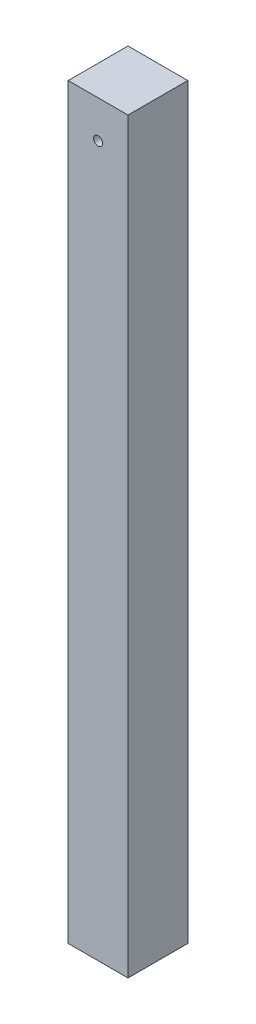
from build123d import *

# Parameters (mm, degrees)
IZIM1_W                     = 80
IZIM1_H                     = 1000
Y_KSEKLIK_EKSTR_ZYON1_DEPTH = 80
KES_EKSTR_ZYON1_REACH       = 82
IZIM2_R                     = 6


with BuildPart() as part:
    # Çizim1 → Yükseklik-Ekstrüzyon1 (new body)
    with BuildSketch(Plane.XY):
        Rectangle(IZIM1_W, IZIM1_H)
    extrude(amount=-Y_KSEKLIK_EKSTR_ZYON1_DEPTH)

    # Çizim2 → Kes-Ekstrüzyon1 (cut, up to next)
    with BuildSketch(Plane.XY, mode=Mode.PRIVATE) as kes_ekstr_zyon1_sk1:
        with Locations((0, 450)):
            Circle(IZIM2_R)
    kes_ekstr_zyon1_tool1 = extrude(kes_ekstr_zyon1_sk1.sketch, amount=-KES_EKSTR_ZYON1_REACH, mode=Mode.PRIVATE) & part.part
    add(kes_ekstr_zyon1_tool1.solids().sort_by_distance((0, 450, 0))[0], mode=Mode.SUBTRACT)


solid = part.part
